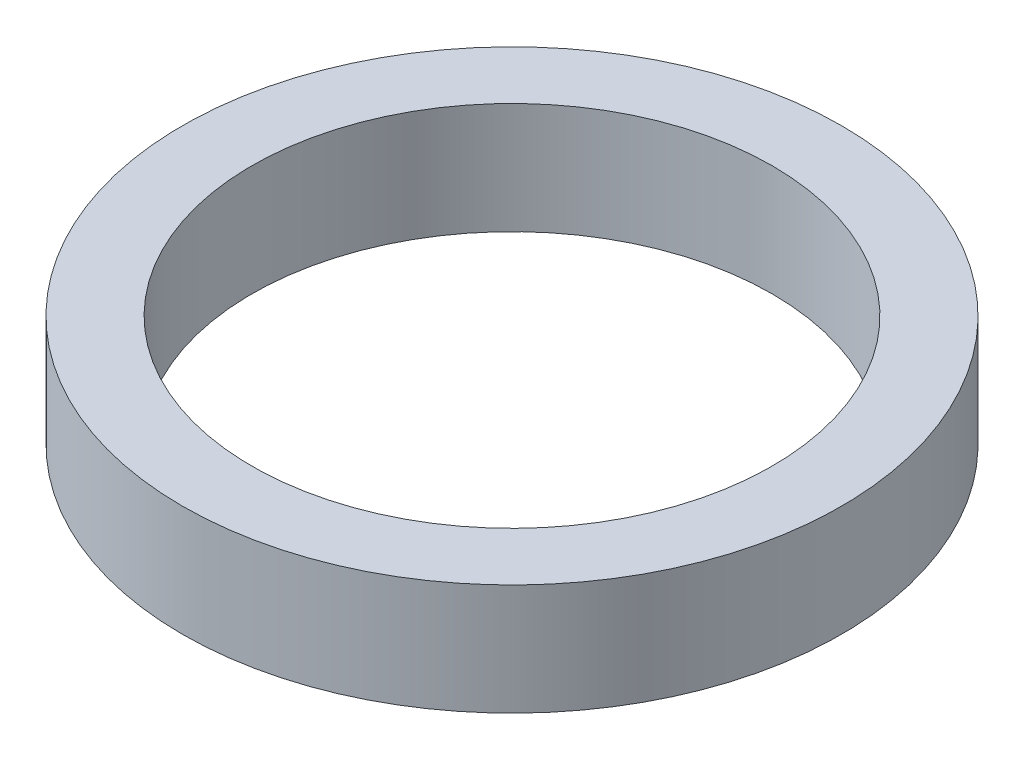
from build123d import *

# Parameters (mm, degrees)
SKETCH1_R           = 30.1625
BOSS_EXTRUDE1_DEPTH = 10.16
SKETCH2_R           = 23.8125
CUT_EXTRUDE1_DEPTH  = 11.16


with BuildPart() as part:
    # Sketch1 → Boss-Extrude1 (new body)
    with BuildSketch(Plane(origin=(0, 0, 0), x_dir=(1, 0, 0), z_dir=(0, 1, 0))):
        Circle(SKETCH1_R)
    extrude(amount=BOSS_EXTRUDE1_DEPTH)

    # Sketch2 → Cut-Extrude1 (cut, through all)
    with BuildSketch(Plane(origin=(0, 0, 0), x_dir=(-1, 0, 0), z_dir=(0, -1, 0))):
        Circle(SKETCH2_R)
    extrude(amount=-CUT_EXTRUDE1_DEPTH, mode=Mode.SUBTRACT)


solid = part.part
